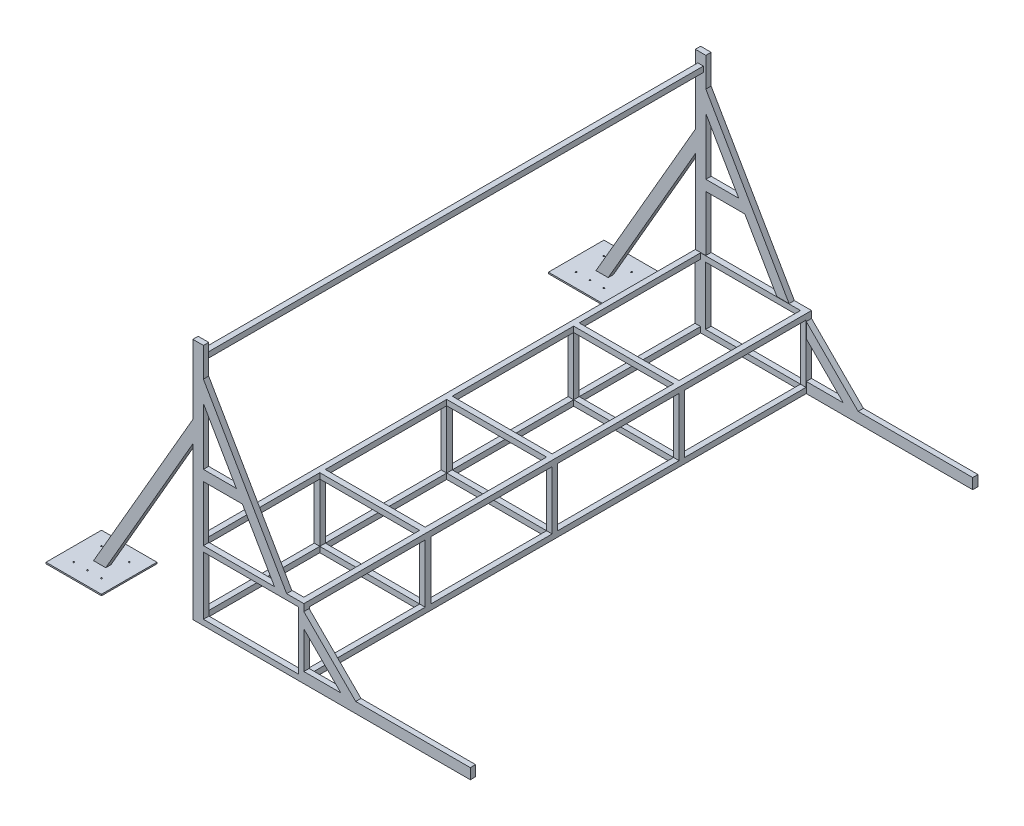
from build123d import *

# Parameters (mm, degrees)
SKETCH1_W               = 800
SKETCH1_H               = 500
BOSS_EXTRUDE5_DEPTH     = 3660
BOSS_EXTRUDE5_2_DEPTH   = 3660
BOSS_EXTRUDE2_DEPTH     = 38
SKETCH4_W               = 684
SKETCH4_H               = 420
CUT_EXTRUDE1_DEPTH      = 3661
CUT_EXTRUDE2_DEPTH      = 1790
CUT_EXTRUDE2_DEPTH_BACK = 1790
BOSS_EXTRUDE3_DEPTH     = 76
SKETCH9_W               = 400
SKETCH9_H               = 400
BOSS_EXTRUDE6_DEPTH     = 10
BOSS_EXTRUDE6_2_DEPTH   = 10
SKETCH11_W              = 40
SKETCH11_H              = 40
BOSS_EXTRUDE7_DEPTH     = 3584
SKETCH12_W              = 40
SKETCH12_H              = 40
BOSS_EXTRUDE8_DEPTH     = 420
LPATTERN1_COUNT         = 4
LPATTERN1_PITCH         = 915
LPATTERN1_COUNT_DIR2    = 2
LPATTERN1_PITCH_DIR2    = 760
SKETCH13_W              = 40
SKETCH13_H              = 40
BOSS_EXTRUDE9_DEPTH     = 760
LPATTERN2_COUNT         = 4
LPATTERN2_PITCH         = 915
LPATTERN2_COUNT_DIR2    = 2
LPATTERN2_PITCH_DIR2    = 460
SKETCH14_W              = 4140.847934345
SKETCH14_H              = 3535.849458551
CUT_EXTRUDE3_DEPTH      = 182
CUT_EXTRUDE3_DEPTH_BACK = 3842
SKETCH17_W              = 5
SKETCH17_H              = 10
LPATTERN3_COUNT         = 2
LPATTERN3_PITCH         = 200
LPATTERN3_COUNT_DIR2    = 3
LPATTERN3_PITCH_DIR2    = 100
MIRROR3_COPY_1_SKETCH_W = 5
MIRROR3_COPY_1_SKETCH_H = 10
MIRROR3_COPY_2_SKETCH_W = 5
MIRROR3_COPY_2_SKETCH_H = 10
MIRROR3_COPY_3_SKETCH_W = 5
MIRROR3_COPY_3_SKETCH_H = 10
MIRROR3_COPY_4_SKETCH_W = 5
MIRROR3_COPY_4_SKETCH_H = 10
MIRROR3_COPY_5_SKETCH_W = 5
MIRROR3_COPY_5_SKETCH_H = 10


with BuildPart() as part:
    # Sketch1 → Boss-Extrude5 (new body)
    with BuildSketch(Plane.XY):
        with Locations((400, 250)):
            Rectangle(SKETCH1_W, SKETCH1_H)
    extrude(amount=BOSS_EXTRUDE5_DEPTH)

    # Sketch3 → Boss-Extrude2 (add)
    with BuildSketch(Plane.XY):
        Polygon((0, 500), (76, 500), (76, 900), (357.302651407, 900), (588.242759083, 500), (676, 500), (76, 1539.230484541), (76, 1750), (0, 1750), (0, 1250), (-721.687836487, 0), (-633.93059557, 0), (0, 1098), align=None)
        Polygon((76, 1387.230484541), (313.424030949, 976), (76, 976), align=None, mode=Mode.SUBTRACT)
        Polygon((800, 450), (1174, 76), (2000, 76), (2000, 0), (800, 0), (800, 76), (1066.51976926, 76), (800, 342.51976926), align=None)
    boss_extrude2 = extrude(amount=BOSS_EXTRUDE2_DEPTH)

    # Mirror1: Boss-Extrude2 across plane
    add(boss_extrude2.mirror(Plane.XY.offset(1830)))

    # Sketch4 → Cut-Extrude1 (cut, through all)
    with BuildSketch(Plane.XY.offset(3660)):
        with Locations((418, 250)):
            Rectangle(SKETCH4_W, SKETCH4_H)
    extrude(amount=-CUT_EXTRUDE1_DEPTH, mode=Mode.SUBTRACT)

    # Sketch5 → Cut-Extrude2 (cut, two sides)
    with BuildSketch(Plane.XY.offset(1830)) as cut_extrude2_sk:
        Polygon((40, 500), (40, 460), (0, 460), (0, 40), (40, 40), (40, 0), (760, 0), (760, 40), (800, 40), (800, 460), (760, 460), (760, 500), align=None)
    extrude(amount=CUT_EXTRUDE2_DEPTH, mode=Mode.SUBTRACT)
    extrude(cut_extrude2_sk.sketch, amount=-CUT_EXTRUDE2_DEPTH_BACK, mode=Mode.SUBTRACT)

    # Sketch11 → Boss-Extrude7 (add)
    with BuildSketch(Plane.XY.offset(38)):
        with Locations((38, 1654)):
            Rectangle(SKETCH11_W, SKETCH11_H)
    extrude(amount=BOSS_EXTRUDE7_DEPTH)

    # Sketch12 → Boss-Extrude8 (add)
    with BuildSketch(Plane(origin=(0, 40, 0), x_dir=(1, 0, 0), z_dir=(0, 1, 0))):
        with Locations((20, -20)):
            Rectangle(SKETCH12_W, SKETCH12_H)
    boss_extrude8 = extrude(amount=BOSS_EXTRUDE8_DEPTH)

    # LPattern1: Boss-Extrude8 4 × 2
    with Locations(*[(j * LPATTERN1_PITCH_DIR2, 0, i * LPATTERN1_PITCH) for i in range(LPATTERN1_COUNT) for j in range(LPATTERN1_COUNT_DIR2) if (i, j) != (0, 0)]):
        add(boss_extrude8)

    # Sketch13 → Boss-Extrude9 (add)
    with BuildSketch(Plane.ZY.offset(-760)):
        with Locations((20, 480)):
            Rectangle(SKETCH13_W, SKETCH13_H)
    boss_extrude9 = extrude(amount=BOSS_EXTRUDE9_DEPTH)

    # LPattern2: Boss-Extrude9 4 × 2
    with Locations(*[(0, -j * LPATTERN2_PITCH_DIR2, i * LPATTERN2_PITCH) for i in range(LPATTERN2_COUNT) for j in range(LPATTERN2_COUNT_DIR2) if (i, j) != (0, 0)]):
        add(boss_extrude9)


with BuildPart() as body_2:
    # Sketch1 → Boss-Extrude5 2 (new body)
    with BuildSketch(Plane.XY):
        Polygon((2614.411542732, 3678.652977851), (2630, 3669.652977851), (800, 500), (784.411542732, 509), align=None)
    extrude(amount=BOSS_EXTRUDE5_2_DEPTH)


with BuildPart() as body_3:
    # Sketch7 → Boss-Extrude3 (new body)
    with BuildSketch(Plane(origin=(367.905191786, -212.410161514, 0), x_dir=(0, 0, 1), z_dir=(-0.866025404, 0.5, 0))):
        Polygon((1830, 833.012701892), (0, 833.012701892), (0, 4493.012701892), (1830, 4493.012701892), (1830, 4455.012701892), (38, 4455.012701892), (38, 871.012701892), (1830, 871.012701892), align=None)
    boss_extrude3 = extrude(amount=BOSS_EXTRUDE3_DEPTH)

    # Mirror2: Boss-Extrude3 across plane
    add(boss_extrude3.mirror(Plane.XY.offset(1830)))


with BuildPart() as body_4:
    # Sketch9 → Boss-Extrude6 (new body)
    with BuildSketch(Plane.XZ):
        with Locations((-677.809216029, 3641)):
            Rectangle(SKETCH9_W, SKETCH9_H)
    extrude(amount=-BOSS_EXTRUDE6_DEPTH)

    # Sketch17 → Ø10.0mm Dowel Hole1 (revolve, cut)
    with BuildSketch(Plane(origin=(-777.809216029, 10, 3541), x_dir=(0, 0, 1), z_dir=(1, 0, 0))):
        with Locations((2.5, 5)):
            Rectangle(SKETCH17_W, SKETCH17_H)
    f_10_0mm_dowel_hole1 = revolve(axis=Axis((-777.809216029, 16.35, 3541), (0, -1, 0)), mode=Mode.SUBTRACT)

    # LPattern3: 10.0mm Dowel Hole1 2 × 3
    with Locations(*[(j * LPATTERN3_PITCH_DIR2, 0, i * LPATTERN3_PITCH) for i in range(LPATTERN3_COUNT) for j in range(LPATTERN3_COUNT_DIR2) if (i, j) != (0, 0)]):
        add(f_10_0mm_dowel_hole1, mode=Mode.SUBTRACT)


with BuildPart() as body_5:
    # Sketch9 → Boss-Extrude6 2 (new body)
    with BuildSketch(Plane.XZ):
        with Locations((-677.809216029, 19)):
            Rectangle(SKETCH9_W, SKETCH9_H)
    extrude(amount=-BOSS_EXTRUDE6_2_DEPTH)

    # Mirror3: Ø10.0mm Dowel Hole1 across plane
    add(f_10_0mm_dowel_hole1.mirror(Plane.XY.offset(1830)), mode=Mode.SUBTRACT)

    # Mirror3 copy 1 sketch → Mirror3 copy 1 (revolve, cut)
    with BuildSketch(Plane(origin=(-677.809216029, 10, 119), x_dir=(0, 0, -1), z_dir=(1, 0, 0))):
        with Locations((2.5, -5)):
            Rectangle(MIRROR3_COPY_1_SKETCH_W, MIRROR3_COPY_1_SKETCH_H)
    revolve(axis=Axis((-677.809216029, 16.35, 119), (0, 1, 0)), mode=Mode.SUBTRACT)

    # Mirror3 copy 2 sketch → Mirror3 copy 2 (revolve, cut)
    with BuildSketch(Plane(origin=(-577.809216029, 10, 119), x_dir=(0, 0, -1), z_dir=(1, 0, 0))):
        with Locations((2.5, -5)):
            Rectangle(MIRROR3_COPY_2_SKETCH_W, MIRROR3_COPY_2_SKETCH_H)
    revolve(axis=Axis((-577.809216029, 16.35, 119), (0, 1, 0)), mode=Mode.SUBTRACT)

    # Mirror3 copy 3 sketch → Mirror3 copy 3 (revolve, cut)
    with BuildSketch(Plane(origin=(-777.809216029, 10, -81), x_dir=(0, 0, -1), z_dir=(1, 0, 0))):
        with Locations((2.5, -5)):
            Rectangle(MIRROR3_COPY_3_SKETCH_W, MIRROR3_COPY_3_SKETCH_H)
    revolve(axis=Axis((-777.809216029, 16.35, -81), (0, 1, 0)), mode=Mode.SUBTRACT)

    # Mirror3 copy 4 sketch → Mirror3 copy 4 (revolve, cut)
    with BuildSketch(Plane(origin=(-677.809216029, 10, -81), x_dir=(0, 0, -1), z_dir=(1, 0, 0))):
        with Locations((2.5, -5)):
            Rectangle(MIRROR3_COPY_4_SKETCH_W, MIRROR3_COPY_4_SKETCH_H)
    revolve(axis=Axis((-677.809216029, 16.35, -81), (0, 1, 0)), mode=Mode.SUBTRACT)

    # Mirror3 copy 5 sketch → Mirror3 copy 5 (revolve, cut)
    with BuildSketch(Plane(origin=(-577.809216029, 10, -81), x_dir=(0, 0, -1), z_dir=(1, 0, 0))):
        with Locations((2.5, -5)):
            Rectangle(MIRROR3_COPY_5_SKETCH_W, MIRROR3_COPY_5_SKETCH_H)
    revolve(axis=Axis((-577.809216029, 16.35, -81), (0, 1, 0)), mode=Mode.SUBTRACT)


with BuildPart() as cut_extrude3_tool:
    # Sketch14 → Cut-Extrude3 (new body, two sides)
    with BuildSketch(Plane.XY.offset(3660)) as cut_extrude3_sk:
        with Locations((2687.602754195, 2267.924729276)):
            Rectangle(SKETCH14_W, SKETCH14_H)
    extrude(amount=CUT_EXTRUDE3_DEPTH)
    extrude(cut_extrude3_sk.sketch, amount=-CUT_EXTRUDE3_DEPTH_BACK)


with BuildPart() as body_3_1:
    add(body_3.part)

    # Cut-Extrude3: cut by cut_extrude3_tool
    add(cut_extrude3_tool.part, mode=Mode.SUBTRACT)


with BuildPart() as body_2_1:
    add(body_2.part)

    # Cut-Extrude3: cut by cut_extrude3_tool
    add(cut_extrude3_tool.part, mode=Mode.SUBTRACT)


solid = Compound([part.part, body_4.part, body_5.part])
